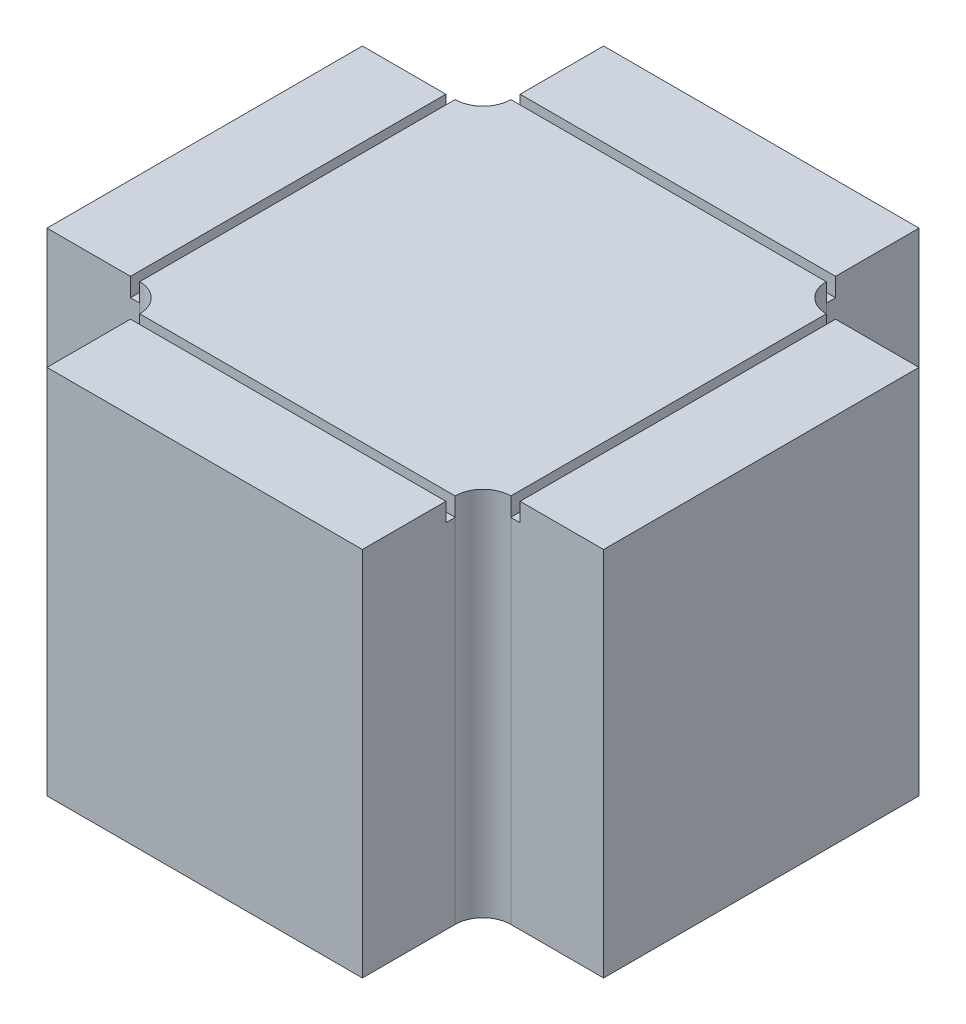
from build123d import *

# Parameters (mm, degrees)
BOSS_EXTRUDE1_DEPTH = 40
SKETCH3_W           = 42
SKETCH3_H           = 42
SKETCH3_W_2         = 40
SKETCH3_H_2         = 40
CUT_EXTRUDE2_DEPTH  = 2


with BuildPart() as part:
    # Sketch1 → Boss-Extrude1 (new body)
    with BuildSketch(Plane(origin=(0, 0, 0), x_dir=(1, 0, 0), z_dir=(0, 1, 0))):
        with BuildLine():
            ThreePointArc((-17, 20), (-17.878679656, 17.878679656), (-20, 17))
            Line((-20, 17), (-30, 17))
            Line((-30, 17), (-30, -17))
            Line((-30, -17), (-20, -17))
            ThreePointArc((-20, -17), (-17.878679656, -17.878679656), (-17, -20))
            Line((-17, -20), (-17, -30))
            Line((-17, -30), (17, -30))
            Line((17, -30), (17, -20))
            ThreePointArc((17, -20), (17.878679656, -17.878679656), (20, -17))
            Line((20, -17), (30, -17))
            Line((30, -17), (30, 17))
            Line((30, 17), (20, 17))
            ThreePointArc((20, 17), (17.878679656, 17.878679656), (17, 20))
            Line((17, 20), (17, 30))
            Line((17, 30), (-17, 30))
            Line((-17, 30), (-17, 20))
        make_face()
    extrude(amount=BOSS_EXTRUDE1_DEPTH)

    # Sketch3 → Cut-Extrude2 (cut)
    with BuildSketch(Plane(origin=(0, 40, 0), x_dir=(1, 0, 0), z_dir=(0, 1, 0))):
        Rectangle(SKETCH3_W, SKETCH3_H)
        Rectangle(SKETCH3_W_2, SKETCH3_H_2, mode=Mode.SUBTRACT)
    extrude(amount=-CUT_EXTRUDE2_DEPTH, mode=Mode.SUBTRACT)


solid = part.part
